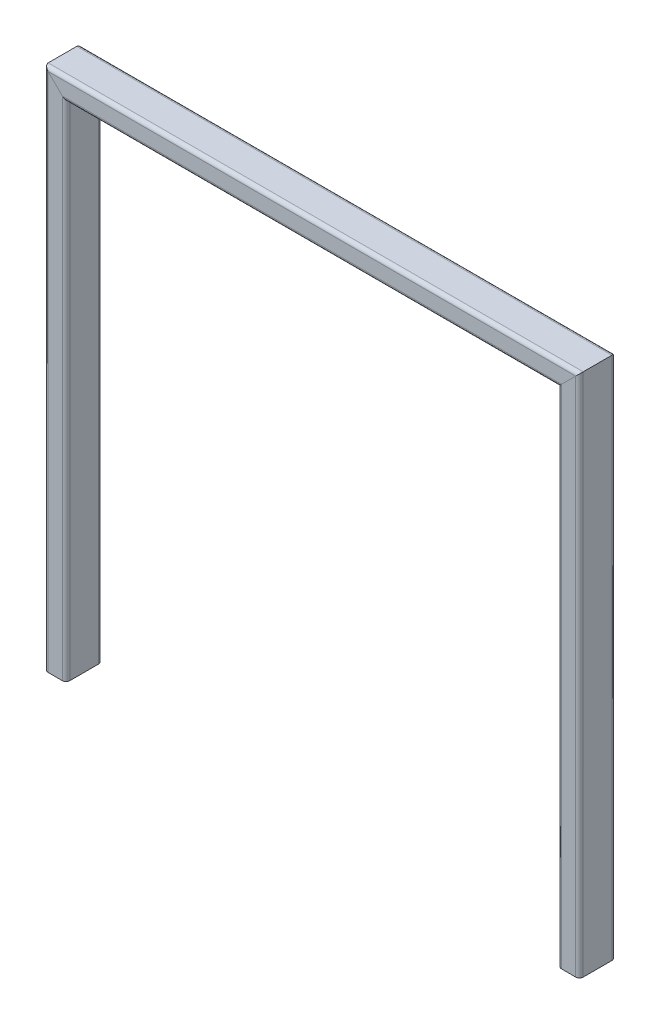
from build123d import *

# Parameters (mm, degrees)
RECTANGULAR_TUBE_50_X_30_X_2_6_1_DEPTH   = 741.354759474
RECTANGULAR_TUBE_50_X_30_X_2_6_1_2_DEPTH = 771.509518948
RECTANGULAR_TUBE_50_X_30_X_2_6_1_3_DEPTH = 741.354759474


with BuildPart() as part:
    # Sketch11 → Rectangular tube 50 X 30 X 2.6(1) (new body)
    with BuildSketch(Plane(origin=(0, 0, 0), x_dir=(1, 0, 0), z_dir=(0, 1, 0))):
        with BuildLine():
            Line((-9.8, -25), (9.8, -25))
            ThreePointArc((9.8, -25), (13.476955262, -23.476955262), (15, -19.8))
            Line((15, -19.8), (15, 19.8))
            ThreePointArc((15, 19.8), (13.476955262, 23.476955262), (9.8, 25))
            Line((9.8, 25), (-9.8, 25))
            ThreePointArc((-9.8, 25), (-13.476955262, 23.476955262), (-15, 19.8))
            Line((-15, 19.8), (-15, -19.8))
            ThreePointArc((-15, -19.8), (-13.476955262, -23.476955262), (-9.8, -25))
        make_face()
        with BuildLine():
            Line((-9.8, -22.4), (9.8, -22.4))
            ThreePointArc((9.8, -22.4), (11.638477631, -21.638477631), (12.4, -19.8))
            Line((12.4, -19.8), (12.4, 19.8))
            ThreePointArc((12.4, 19.8), (11.638477631, 21.638477631), (9.8, 22.4))
            Line((9.8, 22.4), (-9.8, 22.4))
            ThreePointArc((-9.8, 22.4), (-11.638477631, 21.638477631), (-12.4, 19.8))
            Line((-12.4, 19.8), (-12.4, -19.8))
            ThreePointArc((-12.4, -19.8), (-11.638477631, -21.638477631), (-9.8, -22.4))
        make_face(mode=Mode.SUBTRACT)
    extrude(amount=RECTANGULAR_TUBE_50_X_30_X_2_6_1_DEPTH)

    # Rectangular tube 50 X 30 X 2.6(1) mitre 1
    split(bisect_by=Plane(origin=(0, 711.2, 0), x_dir=(0.707106781, -0.707106781, 0), z_dir=(-0.707106781, -0.707106781, 0)), keep=Keep.TOP)


with BuildPart() as body_2:
    # Sketch11 on segment 2 (carried to segment 2) → Rectangular tube 50 X 30 X 2.6_1 2 (new body)
    with BuildSketch(Plane(origin=(-30.154759474, 711.2, 0), x_dir=(0, -1, 0), z_dir=(1, 0, 0))):
        with BuildLine():
            Line((-9.8, -25), (9.8, -25))
            ThreePointArc((9.8, -25), (13.476955262, -23.476955262), (15, -19.8))
            Line((15, -19.8), (15, 19.8))
            ThreePointArc((15, 19.8), (13.476955262, 23.476955262), (9.8, 25))
            Line((9.8, 25), (-9.8, 25))
            ThreePointArc((-9.8, 25), (-13.476955262, 23.476955262), (-15, 19.8))
            Line((-15, 19.8), (-15, -19.8))
            ThreePointArc((-15, -19.8), (-13.476955262, -23.476955262), (-9.8, -25))
        make_face()
        with BuildLine():
            Line((-9.8, -22.4), (9.8, -22.4))
            ThreePointArc((9.8, -22.4), (11.638477631, -21.638477631), (12.4, -19.8))
            Line((12.4, -19.8), (12.4, 19.8))
            ThreePointArc((12.4, 19.8), (11.638477631, 21.638477631), (9.8, 22.4))
            Line((9.8, 22.4), (-9.8, 22.4))
            ThreePointArc((-9.8, 22.4), (-11.638477631, 21.638477631), (-12.4, 19.8))
            Line((-12.4, 19.8), (-12.4, -19.8))
            ThreePointArc((-12.4, -19.8), (-11.638477631, -21.638477631), (-9.8, -22.4))
        make_face(mode=Mode.SUBTRACT)
    extrude(amount=RECTANGULAR_TUBE_50_X_30_X_2_6_1_2_DEPTH)

    # Rectangular tube 50 X 30 X 2.6_1 2 mitre
    split(bisect_by=Plane(origin=(0, 711.2, 0), x_dir=(-0.707106781, 0.707106781, 0), z_dir=(0.707106781, 0.707106781, 0)), keep=Keep.TOP)

    # Rectangular tube 50 X 30 X 2.6_1 2 m 2
    split(bisect_by=Plane(origin=(711.2, 711.2, 0), x_dir=(-0.707106781, -0.707106781, 0), z_dir=(-0.707106781, 0.707106781, 0)), keep=Keep.TOP)


with BuildPart() as body_3:
    # Sketch11 on segment 3 (carried to segment 3) → Rectangular tube 50 X 30 X 2.6_1 3 (new body)
    with BuildSketch(Plane(origin=(711.2, 741.354759474, 0), x_dir=(-1, 0, 0), z_dir=(0, -1, 0))):
        with BuildLine():
            Line((-9.8, -25), (9.8, -25))
            ThreePointArc((9.8, -25), (13.476955262, -23.476955262), (15, -19.8))
            Line((15, -19.8), (15, 19.8))
            ThreePointArc((15, 19.8), (13.476955262, 23.476955262), (9.8, 25))
            Line((9.8, 25), (-9.8, 25))
            ThreePointArc((-9.8, 25), (-13.476955262, 23.476955262), (-15, 19.8))
            Line((-15, 19.8), (-15, -19.8))
            ThreePointArc((-15, -19.8), (-13.476955262, -23.476955262), (-9.8, -25))
        make_face()
        with BuildLine():
            Line((-9.8, -22.4), (9.8, -22.4))
            ThreePointArc((9.8, -22.4), (11.638477631, -21.638477631), (12.4, -19.8))
            Line((12.4, -19.8), (12.4, 19.8))
            ThreePointArc((12.4, 19.8), (11.638477631, 21.638477631), (9.8, 22.4))
            Line((9.8, 22.4), (-9.8, 22.4))
            ThreePointArc((-9.8, 22.4), (-11.638477631, 21.638477631), (-12.4, 19.8))
            Line((-12.4, 19.8), (-12.4, -19.8))
            ThreePointArc((-12.4, -19.8), (-11.638477631, -21.638477631), (-9.8, -22.4))
        make_face(mode=Mode.SUBTRACT)
    extrude(amount=RECTANGULAR_TUBE_50_X_30_X_2_6_1_3_DEPTH)

    # Rectangular tube 50 X 30 X 2.6_1 3 mitre
    split(bisect_by=Plane(origin=(711.2, 711.2, 0), x_dir=(0.707106781, 0.707106781, 0), z_dir=(0.707106781, -0.707106781, 0)), keep=Keep.TOP)


solid = Compound([part.part, body_2.part, body_3.part])
